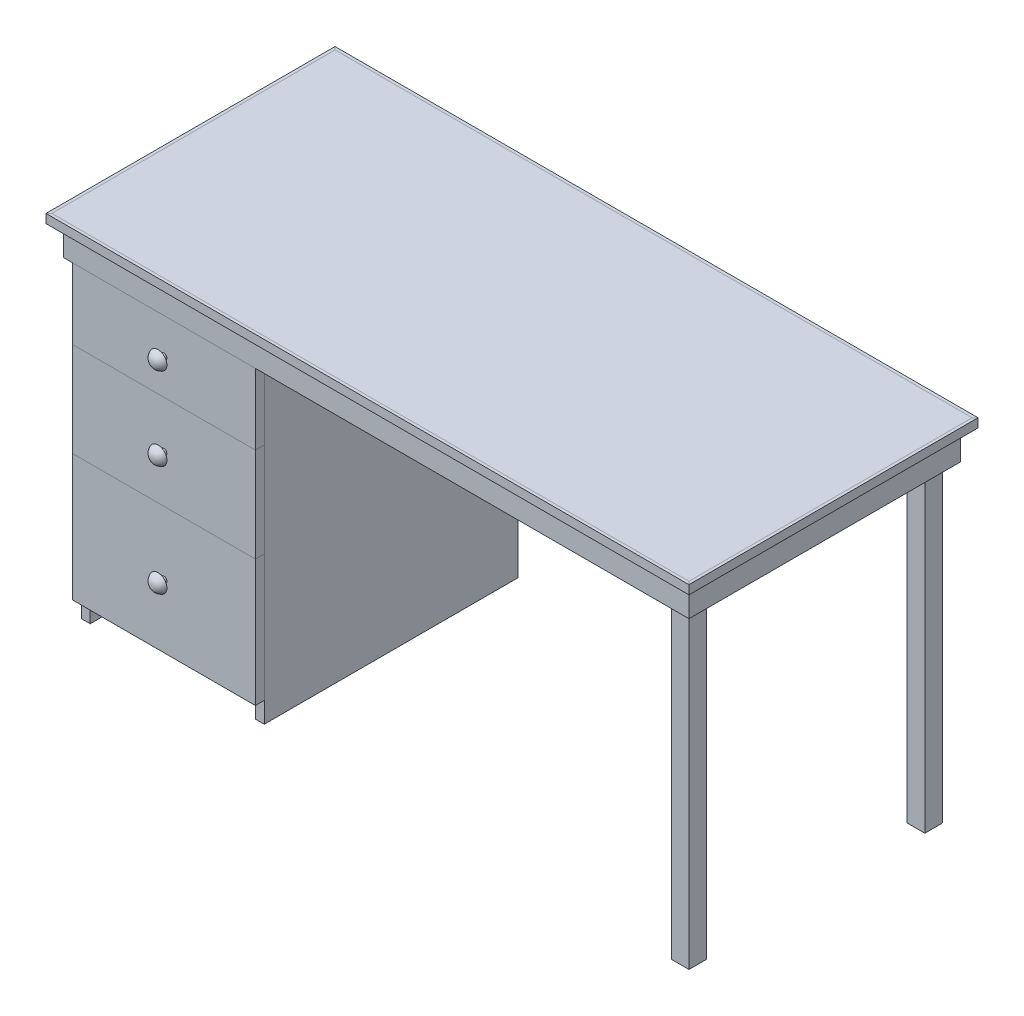
from build123d import *

# Parameters (mm, degrees)
SKETCH1_W                         = 1371.6
SKETCH1_H                         = 609.6
TOP_DEPTH                         = 19.05
TOP_SIDING_FRONT_AND_BACK_DEPTH   = 19.05
TOP_SIDING_FRONT_AND_BACK_2_DEPTH = 19.05
TOP_SIDING_SIDES_DEPTH            = 19.05
TOP_SIDING_SIDES_2_DEPTH          = 19.05
LONG_SIDE_RAILS_DEPTH             = 63.5
LONG_SIDE_RAILS_2_DEPTH           = 63.5
SHORT_SIDE_RAILS_DEPTH            = 63.5
SHORT_SIDE_RAILS_2_DEPTH          = 63.5
SKETCH4_W                         = 38.1
SKETCH4_H                         = 38.1
LEGS_DEPTH                        = 736.6
SKETCH5_W                         = 19.05
SKETCH5_H                         = 546.1
CASE_SIDES_DEPTH                  = 736.6
CASE_SIDES_2_DEPTH                = 736.6
SKETCH6_W                         = 355.6
SKETCH6_H                         = 546.1
CASE_TOP_DEPTH                    = 19.05
SKETCH7_W                         = 355.6
SKETCH7_H                         = 546.1
CASE_BOTTOM_DEPTH                 = 19.05
BRACING_DEPTH                     = 63.5
BRACING_2_DEPTH                   = 63.5
SKETCH11_W                        = 393.7
SKETCH11_H                        = 152.4
TOP_DRAWER_FRONT_DEPTH            = 19.05
SKETCH12_W                        = 393.7
SKETCH12_H                        = 203.2
MIDDLE_DRAWER_FRONT_DEPTH         = 19.05
SKETCH13_W                        = 393.7
SKETCH13_H                        = 273.05
BOTTOM_DRAWER_FRONT_DEPTH         = 19.05
ALL_DRAWER_SIDES_DEPTH            = 355.6
ALL_DRAWER_SIDES_2_DEPTH          = 355.6
ALL_DRAWER_SIDES_3_DEPTH          = 355.6
ALL_DRAWER_SIDES_4_DEPTH          = 355.6
ALL_DRAWER_SIDES_5_DEPTH          = 355.6
ALL_DRAWER_SIDES_6_DEPTH          = 355.6
ALL_DRAWER_FRONT_AND_BACK_DEPTH   = 304.8
ALL_DRAWER_FRONT_AND_BACK_2_DEPTH = 304.8
ALL_DRAWER_FRONT_AND_BACK_3_DEPTH = 304.8
ALL_DRAWER_FRONT_AND_BACK_4_DEPTH = 304.8
ALL_DRAWER_FRONT_AND_BACK_5_DEPTH = 304.8
ALL_DRAWER_FRONT_AND_BACK_6_DEPTH = 304.8
ALL_DRAWER_BOTTOMS_DEPTH          = 342.9
ALL_DRAWER_BOTTOMS_2_DEPTH        = 342.9
ALL_DRAWER_BOTTOMS_3_DEPTH        = 342.9
SKETCH31_W                        = 12.7
SKETCH31_H                        = 12.7
SLIDING_RAILS_DEPTH               = 355.6
SLIDING_RAILS_2_DEPTH             = 355.6
SLIDING_RAILS_3_DEPTH             = 355.6
SLIDING_RAILS_4_DEPTH             = 355.6
SLIDING_RAILS_5_DEPTH             = 355.6
SLIDING_RAILS_6_DEPTH             = 355.6


with BuildPart() as part:
    # Sketch1 → Top (new body)
    with BuildSketch(Plane(origin=(0, 0, 0), x_dir=(1, 0, 0), z_dir=(0, 1, 0))):
        Rectangle(SKETCH1_W, SKETCH1_H)
    extrude(amount=-TOP_DEPTH)



with BuildPart() as body_2:
    # Sketch26 → Top Siding Front and Back (new body)
    with BuildSketch(Plane(origin=(0, 0, 0), x_dir=(1, 0, 0), z_dir=(0, 1, 0))):
        Polygon((-692.15, -311.15), (-685.8, -304.8), (685.8, -304.8), (692.15, -311.15), align=None)
    extrude(amount=-TOP_SIDING_FRONT_AND_BACK_DEPTH)


with BuildPart() as body_3:
    # Sketch26 → Top Siding Front and Back 2 (new body)
    with BuildSketch(Plane(origin=(0, 0, 0), x_dir=(1, 0, 0), z_dir=(0, 1, 0))):
        Polygon((692.15, 311.15), (-692.15, 311.15), (-685.8, 304.8), (685.8, 304.8), align=None)
    extrude(amount=-TOP_SIDING_FRONT_AND_BACK_2_DEPTH)


with BuildPart() as body_4:
    # Sketch27 → Top Siding Sides (new body)
    with BuildSketch(Plane(origin=(0, 0, 0), x_dir=(1, 0, 0), z_dir=(0, 1, 0))):
        Polygon((-692.15, 311.15), (-692.15, -311.15), (-685.8, -304.8), (-685.8, 304.8), align=None)
    extrude(amount=-TOP_SIDING_SIDES_DEPTH)


with BuildPart() as body_5:
    # Sketch27 → Top Siding Sides 2 (new body)
    with BuildSketch(Plane(origin=(0, 0, 0), x_dir=(1, 0, 0), z_dir=(0, 1, 0))):
        Polygon((685.8, 304.8), (685.8, -304.8), (692.15, -311.15), (692.15, 311.15), align=None)
    extrude(amount=-TOP_SIDING_SIDES_2_DEPTH)


with BuildPart() as body_6:
    # Sketch2 → Long Side Rails (new body)
    with BuildSketch(Plane.XZ.offset(19.05)):
        Polygon((-673.1, 292.1), (-654.05, 273.05), (654.05, 273.05), (673.1, 292.1), align=None)
    extrude(amount=LONG_SIDE_RAILS_DEPTH)


with BuildPart() as body_7:
    # Sketch2 → Long Side Rails 2 (new body)
    with BuildSketch(Plane.XZ.offset(19.05)):
        Polygon((654.05, -273.05), (673.1, -292.1), (-673.1, -292.1), (-654.05, -273.05), align=None)
    extrude(amount=LONG_SIDE_RAILS_2_DEPTH)


with BuildPart() as body_8:
    # Sketch3 → Short Side Rails (new body)
    with BuildSketch(Plane.XZ.offset(19.05)):
        Polygon((-673.1, 292.1), (-654.05, 273.05), (-654.05, -273.05), (-673.1, -292.1), align=None)
    extrude(amount=SHORT_SIDE_RAILS_DEPTH)


with BuildPart() as body_9:
    # Sketch3 → Short Side Rails 2 (new body)
    with BuildSketch(Plane.XZ.offset(19.05)):
        Polygon((654.05, -273.05), (673.1, -292.1), (673.1, 292.1), (654.05, 273.05), align=None)
    extrude(amount=SHORT_SIDE_RAILS_2_DEPTH)


with BuildPart() as part_1:
    add(part.part)

    add(body_6.part)  # Legs merges body 6

    add(body_7.part)  # Legs merges body 7

    add(body_9.part)  # Legs merges body 9
    # Sketch4 → Legs (add)
    with BuildSketch(Plane.XZ.offset(19.05)):
        with Locations((635, 254)):
            Rectangle(SKETCH4_W, SKETCH4_H)
        with Locations((635, -254)):
            Rectangle(SKETCH4_W, SKETCH4_H)
    extrude(amount=LEGS_DEPTH)


with BuildPart() as body_7_2:
    # Sketch5 → Case Sides (new body)
    with BuildSketch(Plane.XZ.offset(19.05)):
        with Locations((-644.525, 0)):
            Rectangle(SKETCH5_W, SKETCH5_H)
    extrude(amount=CASE_SIDES_DEPTH)


with BuildPart() as body_8_2:
    # Sketch5 → Case Sides 2 (new body)
    with BuildSketch(Plane.XZ.offset(19.05)):
        with Locations((-269.875, 0)):
            Rectangle(SKETCH5_W, SKETCH5_H)
    extrude(amount=CASE_SIDES_2_DEPTH)


with BuildPart() as body_9_2:
    # Sketch6 → Case Top (new body)
    with BuildSketch(Plane.XZ.offset(19.05)):
        with Locations((-457.2, 0)):
            Rectangle(SKETCH6_W, SKETCH6_H)
    extrude(amount=CASE_TOP_DEPTH)


with BuildPart() as body_10:
    # Sketch7 → Case Bottom (new body)
    with BuildSketch(Plane(origin=(0, -685.8, 0), x_dir=(-1, 0, 0), z_dir=(0, -1, 0))):
        with Locations((457.2, 0)):
            Rectangle(SKETCH7_W, SKETCH7_H)
    extrude(amount=CASE_BOTTOM_DEPTH)


with BuildPart() as body_11:
    # Sketch8 → Bracing (new body)
    with BuildSketch(Plane.XZ.offset(19.05)):
        Polygon((577.85, 273.05), (654.05, 196.85), (654.05, 169.909231637), (550.909231637, 273.05), align=None)
    extrude(amount=BRACING_DEPTH)


with BuildPart() as body_12:
    # Sketch8 → Bracing 2 (new body)
    with BuildSketch(Plane.XZ.offset(19.05)):
        Polygon((654.05, -196.85), (654.05, -169.909231637), (550.909231637, -273.05), (577.85, -273.05), align=None)
    extrude(amount=BRACING_2_DEPTH)


with BuildPart() as body_13:
    # Sketch11 → Top Drawer Front (new body)
    with BuildSketch(Plane.XY.offset(273.05)):
        with Locations((-457.2, -158.75)):
            Rectangle(SKETCH11_W, SKETCH11_H)
    extrude(amount=TOP_DRAWER_FRONT_DEPTH)


with BuildPart() as body_14:
    # Sketch12 → Middle Drawer Front (new body)
    with BuildSketch(Plane.XY.offset(273.05)):
        with Locations((-457.2, -336.55)):
            Rectangle(SKETCH12_W, SKETCH12_H)
    extrude(amount=MIDDLE_DRAWER_FRONT_DEPTH)


with BuildPart() as body_15:
    # Sketch13 → Bottom Drawer Front (new body)
    with BuildSketch(Plane.XY.offset(273.05)):
        with Locations((-457.2, -574.675)):
            Rectangle(SKETCH13_W, SKETCH13_H)
    extrude(amount=BOTTOM_DRAWER_FRONT_DEPTH)


with BuildPart() as body_16:
    # Sketch14 → All Drawer Sides (new body)
    with BuildSketch(Plane.XY.offset(273.05)):
        Polygon((-609.6, -95.25), (-609.6, -215.9), (-615.95, -215.9), (-615.95, -222.25), (-609.6, -222.25), (-609.6, -234.95), (-622.3, -234.95), (-622.3, -95.25), align=None)
    extrude(amount=-ALL_DRAWER_SIDES_DEPTH)


with BuildPart() as body_17:
    # Sketch14 → All Drawer Sides 2 (new body)
    with BuildSketch(Plane.XY.offset(273.05)):
        Polygon((-622.3, -450.85), (-622.3, -679.45), (-609.6, -679.45), (-609.6, -666.75), (-615.95, -666.75), (-615.95, -660.4), (-609.6, -660.4), (-609.6, -450.85), align=None)
    extrude(amount=-ALL_DRAWER_SIDES_2_DEPTH)


with BuildPart() as body_18:
    # Sketch14 → All Drawer Sides 3 (new body)
    with BuildSketch(Plane.XY.offset(273.05)):
        Polygon((-622.3, -247.65), (-622.3, -438.15), (-609.6, -438.15), (-609.6, -425.45), (-615.95, -425.45), (-615.95, -419.1), (-609.6, -419.1), (-609.6, -247.65), align=None)
    extrude(amount=-ALL_DRAWER_SIDES_3_DEPTH)


with BuildPart() as body_19:
    # Sketch14 → All Drawer Sides 4 (new body)
    with BuildSketch(Plane.XY.offset(273.05)):
        Polygon((-304.8, -247.65), (-292.1, -247.65), (-292.1, -438.15), (-304.8, -438.15), (-304.8, -425.45), (-298.45, -425.45), (-298.45, -419.1), (-304.8, -419.1), align=None)
    extrude(amount=-ALL_DRAWER_SIDES_4_DEPTH)


with BuildPart() as body_20:
    # Sketch14 → All Drawer Sides 5 (new body)
    with BuildSketch(Plane.XY.offset(273.05)):
        Polygon((-304.8, -450.85), (-292.1, -450.85), (-292.1, -679.45), (-304.8, -679.45), (-304.8, -666.75), (-298.45, -666.75), (-298.45, -660.4), (-304.8, -660.4), align=None)
    extrude(amount=-ALL_DRAWER_SIDES_5_DEPTH)


with BuildPart() as body_21:
    # Sketch14 → All Drawer Sides 6 (new body)
    with BuildSketch(Plane.XY.offset(273.05)):
        Polygon((-304.8, -222.25), (-304.8, -234.95), (-292.1, -234.95), (-292.1, -95.25), (-304.8, -95.25), (-304.8, -215.9), (-298.45, -215.9), (-298.45, -222.25), align=None)
    extrude(amount=-ALL_DRAWER_SIDES_6_DEPTH)


with BuildPart() as body_22:
    # Sketch17 → All Drawer Front and Back (new body)
    with BuildSketch(Plane(origin=(-609.6, 0, 0), x_dir=(0, 0, -1), z_dir=(1, 0, 0))):
        Polygon((-273.05, -95.25), (-273.05, -234.95), (-260.35, -234.95), (-260.35, -222.25), (-266.7, -222.25), (-266.7, -215.9), (-260.35, -215.9), (-260.35, -95.25), align=None)
    extrude(amount=ALL_DRAWER_FRONT_AND_BACK_DEPTH)


with BuildPart() as body_23:
    # Sketch17 → All Drawer Front and Back 2 (new body)
    with BuildSketch(Plane(origin=(-609.6, 0, 0), x_dir=(0, 0, -1), z_dir=(1, 0, 0))):
        Polygon((-273.05, -247.65), (-260.35, -247.65), (-260.35, -419.1), (-266.7, -419.1), (-266.7, -425.45), (-260.35, -425.45), (-260.35, -438.15), (-273.05, -438.15), align=None)
    extrude(amount=ALL_DRAWER_FRONT_AND_BACK_2_DEPTH)


with BuildPart() as body_24:
    # Sketch17 → All Drawer Front and Back 3 (new body)
    with BuildSketch(Plane(origin=(-609.6, 0, 0), x_dir=(0, 0, -1), z_dir=(1, 0, 0))):
        Polygon((-260.35, -450.85), (-273.05, -450.85), (-273.05, -679.45), (-260.35, -679.45), (-260.35, -666.75), (-266.7, -666.75), (-266.7, -660.4), (-260.35, -660.4), align=None)
    extrude(amount=ALL_DRAWER_FRONT_AND_BACK_3_DEPTH)


with BuildPart() as body_25:
    # Sketch17 → All Drawer Front and Back 4 (new body)
    with BuildSketch(Plane(origin=(-609.6, 0, 0), x_dir=(0, 0, -1), z_dir=(1, 0, 0))):
        Polygon((69.85, -660.4), (69.85, -450.85), (82.55, -450.85), (82.55, -679.45), (69.85, -679.45), (69.85, -666.75), (76.2, -666.75), (76.2, -660.4), align=None)
    extrude(amount=ALL_DRAWER_FRONT_AND_BACK_4_DEPTH)


with BuildPart() as body_26:
    # Sketch17 → All Drawer Front and Back 5 (new body)
    with BuildSketch(Plane(origin=(-609.6, 0, 0), x_dir=(0, 0, -1), z_dir=(1, 0, 0))):
        Polygon((69.85, -419.1), (69.85, -247.65), (82.55, -247.65), (82.55, -438.15), (69.85, -438.15), (69.85, -425.45), (76.2, -425.45), (76.2, -419.1), align=None)
    extrude(amount=ALL_DRAWER_FRONT_AND_BACK_5_DEPTH)


with BuildPart() as body_27:
    # Sketch17 → All Drawer Front and Back 6 (new body)
    with BuildSketch(Plane(origin=(-609.6, 0, 0), x_dir=(0, 0, -1), z_dir=(1, 0, 0))):
        Polygon((69.85, -95.25), (82.55, -95.25), (82.55, -234.95), (69.85, -234.95), (69.85, -222.25), (76.2, -222.25), (76.2, -215.9), (69.85, -215.9), align=None)
    extrude(amount=ALL_DRAWER_FRONT_AND_BACK_6_DEPTH)


with BuildPart() as body_28:
    # Sketch22 → All Drawer Bottoms (new body)
    with BuildSketch(Plane(origin=(0, 0, 266.7), x_dir=(-1, 0, 0), z_dir=(0, 0, -1))):
        Polygon((304.8, -222.25), (609.6, -222.25), (615.95, -222.25), (615.95, -215.9), (609.6, -215.9), (304.8, -215.9), (298.45, -215.9), (298.45, -222.25), align=None)
    extrude(amount=ALL_DRAWER_BOTTOMS_DEPTH)


with BuildPart() as body_29:
    # Sketch22 → All Drawer Bottoms 2 (new body)
    with BuildSketch(Plane(origin=(0, 0, 266.7), x_dir=(-1, 0, 0), z_dir=(0, 0, -1))):
        Polygon((304.8, -425.45), (609.6, -425.45), (615.95, -425.45), (615.95, -419.1), (609.6, -419.1), (304.8, -419.1), (298.45, -419.1), (298.45, -425.45), align=None)
    extrude(amount=ALL_DRAWER_BOTTOMS_2_DEPTH)


with BuildPart() as body_30:
    # Sketch22 → All Drawer Bottoms 3 (new body)
    with BuildSketch(Plane(origin=(0, 0, 266.7), x_dir=(-1, 0, 0), z_dir=(0, 0, -1))):
        Polygon((304.8, -660.4), (609.6, -660.4), (615.95, -660.4), (615.95, -666.75), (609.6, -666.75), (304.8, -666.75), (298.45, -666.75), (298.45, -660.4), align=None)
    extrude(amount=ALL_DRAWER_BOTTOMS_3_DEPTH)


with BuildPart() as body_31:
    # Sketch28 → Top Drawer Knob (revolve)
    with BuildSketch(Plane(origin=(-457.2, 0, 0), x_dir=(0, 0, -1), z_dir=(1, 0, 0)), mode=Mode.PRIVATE) as top_drawer_knob_sk:
        with BuildLine():
            Line((-304.8, -152.4), (-292.1, -152.4))
            Line((-292.1, -152.4), (-292.1, -158.75))
            Line((-292.1, -158.75), (-317.5, -158.75))
            ThreePointArc((-317.5, -158.75), (-314.331123735, -147.104250843), (-304.8, -139.7))
            Line((-304.8, -139.7), (-304.8, -152.4))
        make_face()
    revolve(top_drawer_knob_sk.sketch.rotate(Axis((-457.2, -158.75, 292.1), (0, 0, 1)), 90), axis=Axis((-457.2, -158.75, 292.1), (0, 0, 1)))  # turned: the seam where the file's is


with BuildPart() as body_32:
    # Sketch29 → Middle Drawer Knob (revolve)
    with BuildSketch(Plane(origin=(-457.2, 0, 0), x_dir=(0, 0, -1), z_dir=(1, 0, 0))):
        with BuildLine():
            Line((-292.1, -330.2), (-304.8, -330.2))
            Line((-304.8, -330.2), (-304.8, -317.5))
            ThreePointArc((-304.8, -317.5), (-314.331123735, -324.904250843), (-317.5, -336.55))
            Line((-317.5, -336.55), (-292.1, -336.55))
            Line((-292.1, -336.55), (-292.1, -330.2))
        make_face()
    revolve(axis=Axis((-457.2, -336.55, 292.1), (0, 0, 1)))


with BuildPart() as body_33:
    # Sketch30 → Bottom Drawer Knob (revolve)
    with BuildSketch(Plane(origin=(-457.2, 0, 0), x_dir=(0, 0, -1), z_dir=(1, 0, 0)), mode=Mode.PRIVATE) as bottom_drawer_knob_sk:
        with BuildLine():
            Line((-292.1, -568.325), (-304.8, -568.325))
            Line((-304.8, -568.325), (-304.8, -555.625))
            ThreePointArc((-304.8, -555.625), (-314.331123735, -563.029250843), (-317.5, -574.675))
            Line((-317.5, -574.675), (-292.1, -574.675))
            Line((-292.1, -574.675), (-292.1, -568.325))
        make_face()
    revolve(bottom_drawer_knob_sk.sketch.rotate(Axis((-457.2, -574.675, 317.5), (0, 0, -1)), 90), axis=Axis((-457.2, -574.675, 317.5), (0, 0, -1)))  # turned: the seam where the file's is


with BuildPart() as body_34:
    # Sketch31 → Sliding Rails (new body)
    with BuildSketch(Plane(origin=(0, 0, 273.05), x_dir=(-1, 0, 0), z_dir=(0, 0, -1))):
        with Locations((285.75, -228.6)):
            Rectangle(SKETCH31_W, SKETCH31_H)
    extrude(amount=SLIDING_RAILS_DEPTH)


with BuildPart() as body_35:
    # Sketch31 → Sliding Rails 2 (new body)
    with BuildSketch(Plane(origin=(0, 0, 273.05), x_dir=(-1, 0, 0), z_dir=(0, 0, -1))):
        with Locations((628.65, -228.6)):
            Rectangle(SKETCH31_W, SKETCH31_H)
    extrude(amount=SLIDING_RAILS_2_DEPTH)


with BuildPart() as body_36:
    # Sketch31 → Sliding Rails 3 (new body)
    with BuildSketch(Plane(origin=(0, 0, 273.05), x_dir=(-1, 0, 0), z_dir=(0, 0, -1))):
        with Locations((285.75, -431.8)):
            Rectangle(SKETCH31_W, SKETCH31_H)
    extrude(amount=SLIDING_RAILS_3_DEPTH)


with BuildPart() as body_37:
    # Sketch31 → Sliding Rails 4 (new body)
    with BuildSketch(Plane(origin=(0, 0, 273.05), x_dir=(-1, 0, 0), z_dir=(0, 0, -1))):
        with Locations((285.75, -673.1)):
            Rectangle(SKETCH31_W, SKETCH31_H)
    extrude(amount=SLIDING_RAILS_4_DEPTH)


with BuildPart() as body_38:
    # Sketch31 → Sliding Rails 5 (new body)
    with BuildSketch(Plane(origin=(0, 0, 273.05), x_dir=(-1, 0, 0), z_dir=(0, 0, -1))):
        with Locations((628.65, -673.1)):
            Rectangle(SKETCH31_W, SKETCH31_H)
    extrude(amount=SLIDING_RAILS_5_DEPTH)


with BuildPart() as body_39:
    # Sketch31 → Sliding Rails 6 (new body)
    with BuildSketch(Plane(origin=(0, 0, 273.05), x_dir=(-1, 0, 0), z_dir=(0, 0, -1))):
        with Locations((628.65, -431.8)):
            Rectangle(SKETCH31_W, SKETCH31_H)
    extrude(amount=SLIDING_RAILS_6_DEPTH)


solid = Compound([body_2.part, body_3.part, body_4.part, body_5.part, body_8.part, part_1.part, body_7_2.part, body_8_2.part, body_9_2.part, body_10.part, body_11.part, body_12.part, body_13.part, body_14.part, body_15.part, body_16.part, body_17.part, body_18.part, body_19.part, body_20.part, body_21.part, body_22.part, body_23.part, body_24.part, body_25.part, body_26.part, body_27.part, body_28.part, body_29.part, body_30.part, body_31.part, body_32.part, body_33.part, body_34.part, body_35.part, body_36.part, body_37.part, body_38.part, body_39.part])
